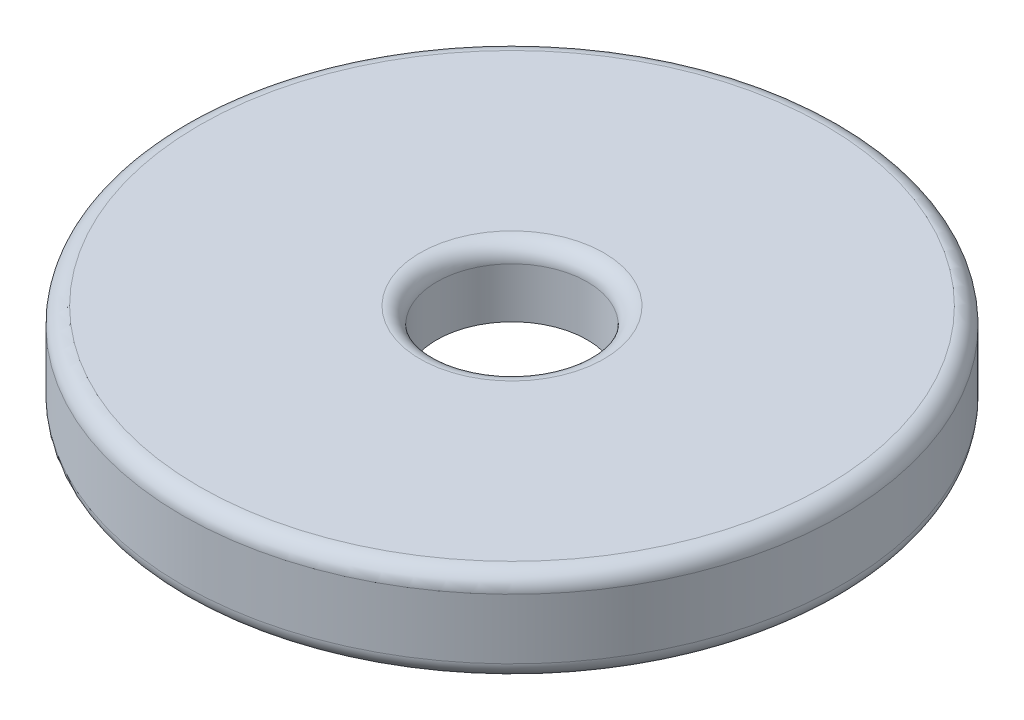
from build123d import *

# Parameters (mm, degrees)
FILLET1_R = 0.5


with BuildPart() as part:
    # Sketch1 → Revolve1 (revolve)
    with BuildSketch(Plane.XY):
        Polygon((-2.2479, 0), (-2.2479, 2), (-9.8479, 2), (-9.8479, -0.8), (-8.3479, -0.8), (-8.3479, 0), align=None)
    revolve(axis=Axis((0, 0, 0), (0, 1, 0)))

    # Fillet1
    fillet1_edges = [part.edges().sort_by_distance(p)[0] for p in [
        (8.3479, -0.8, 0),
        (9.8479, -0.8, 0),
        (9.8479, 2, 0),
        (2.2479, 2, 0),
    ]]
    fillet(fillet1_edges, radius=FILLET1_R)


solid = part.part
